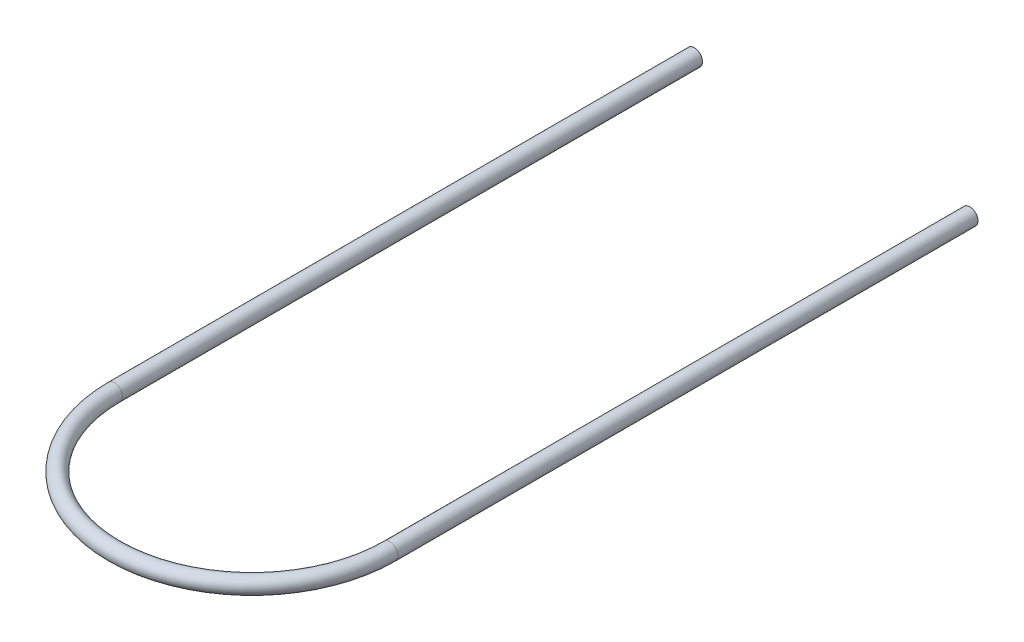
from build123d import *

# Parameters (mm, degrees)
SWEEP3_PROFILE_R = 14.224


with BuildPart() as part:
    # Sweep3: sweep along a path in Sketch2
    with BuildLine(Plane(origin=(0, 0, 0), x_dir=(1, 0, 0), z_dir=(0, 1, 0))) as sweep3_path:
        Line((-241.3, 1016), (-241.3, 0))
        ThreePointArc((-241.3, 0), (0, -241.3), (241.3, 0))
        Line((241.3, 0), (241.3, 1016))
    # Sweep3 profile (on start of the path) → Sweep3 (sweep)
    with BuildSketch(Plane(origin=(-241.3, 0, -1016), x_dir=(1, 0, 0), z_dir=(0, 0, 1))):
        Circle(SWEEP3_PROFILE_R)
    sweep(path=sweep3_path.line)


solid = part.part
